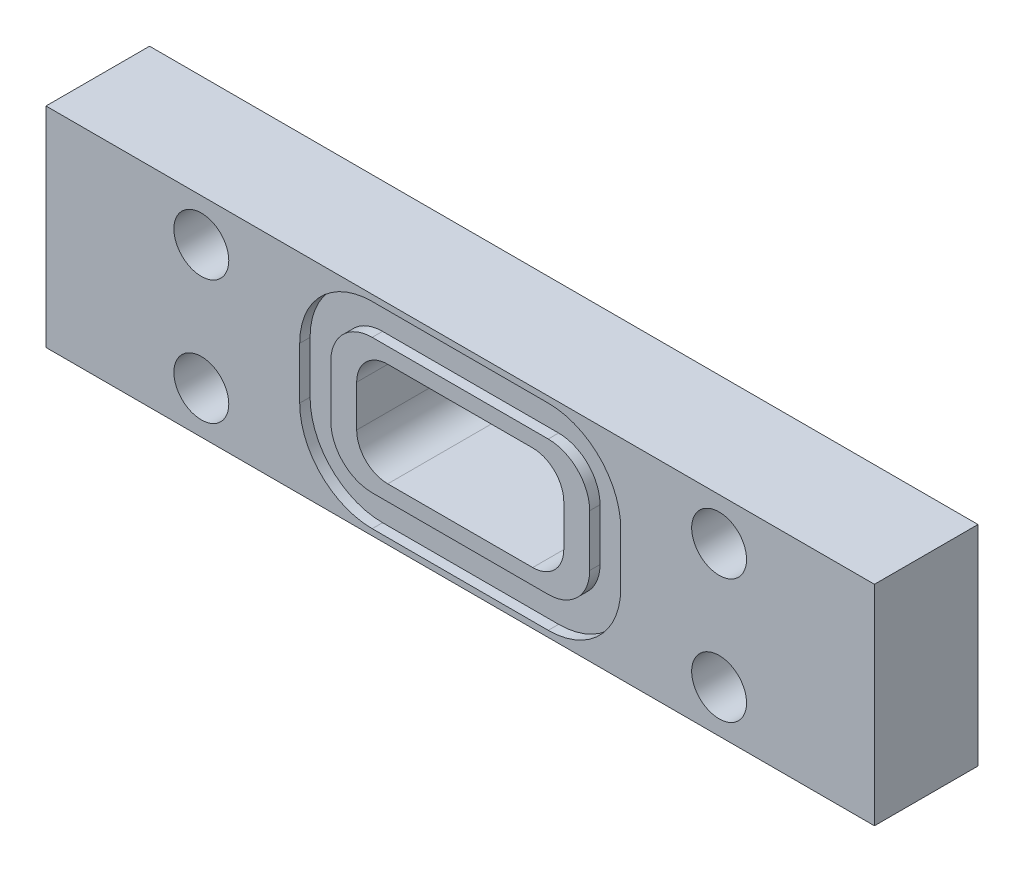
from build123d import *

# Parameters (mm, degrees)
SKIZZE1_W                       = 80
SKIZZE1_H                       = 20.2
SKIZZE1_R                       = 2.65
SKIZZE1_W_2                     = 20
SKIZZE1_H_2                     = 10
AUFSATZ_LINEAR_AUSTRAGEN1_DEPTH = 10
VERRUNDUNG1_R                   = 3
SCHNITT_LINEAR_AUSTRAGEN1_DEPTH = 1


with BuildPart() as part:
    # Skizze1 → Aufsatz-Linear austragen1 (new body)
    with BuildSketch(Plane.XY):
        with Locations((40, 10.1)):
            Rectangle(SKIZZE1_W, SKIZZE1_H)
        with Locations((15, 16.1)):
            Circle(SKIZZE1_R, mode=Mode.SUBTRACT)
        with Locations((15, 4.1)):
            Circle(SKIZZE1_R, mode=Mode.SUBTRACT)
        with Locations((65, 16.1)):
            Circle(SKIZZE1_R, mode=Mode.SUBTRACT)
        with Locations((65, 4.1)):
            Circle(SKIZZE1_R, mode=Mode.SUBTRACT)
        with Locations((40, 10.1)):
            Rectangle(SKIZZE1_W_2, SKIZZE1_H_2, mode=Mode.SUBTRACT)
    extrude(amount=AUFSATZ_LINEAR_AUSTRAGEN1_DEPTH)

    # Verrundung1
    verrundung1_edges = [part.edges().sort_by_distance(p)[0] for p in [
        (50, 5.1, 5),
        (50, 15.1, 5),
        (30, 15.1, 5),
        (30, 5.1, 5),
    ]]
    fillet(verrundung1_edges, radius=VERRUNDUNG1_R)

    # Skizze2 → Schnitt-Linear austragen1 (cut)
    with BuildSketch(Plane.XY.offset(10)):
        with BuildLine():
            Line((55.5, 12.6), (55.5, 7.6))
            ThreePointArc((55.5, 7.6), (53.449747468, 2.650252532), (48.5, 0.6))
            Line((48.5, 0.6), (31.5, 0.6))
            ThreePointArc((31.5, 0.6), (26.550252532, 2.650252532), (24.5, 7.6))
            Line((24.5, 7.6), (24.5, 12.6))
            ThreePointArc((24.5, 12.6), (26.550252532, 17.549747468), (31.5, 19.6))
            Line((31.5, 19.6), (48.5, 19.6))
            ThreePointArc((48.5, 19.6), (53.449747468, 17.549747468), (55.5, 12.6))
        make_face()
        with BuildLine():
            Line((48.5, 16.6), (31.5, 16.6))
            ThreePointArc((31.5, 16.6), (28.671572875, 15.428427125), (27.5, 12.6))
            Line((27.5, 12.6), (27.5, 7.6))
            ThreePointArc((27.5, 7.6), (28.671572875, 4.771572875), (31.5, 3.6))
            Line((31.5, 3.6), (48.5, 3.6))
            ThreePointArc((48.5, 3.6), (51.328427125, 4.771572875), (52.5, 7.6))
            Line((52.5, 7.6), (52.5, 12.6))
            ThreePointArc((52.5, 12.6), (51.328427125, 15.428427125), (48.5, 16.6))
        make_face(mode=Mode.SUBTRACT)
    extrude(amount=-SCHNITT_LINEAR_AUSTRAGEN1_DEPTH, mode=Mode.SUBTRACT)


solid = part.part
